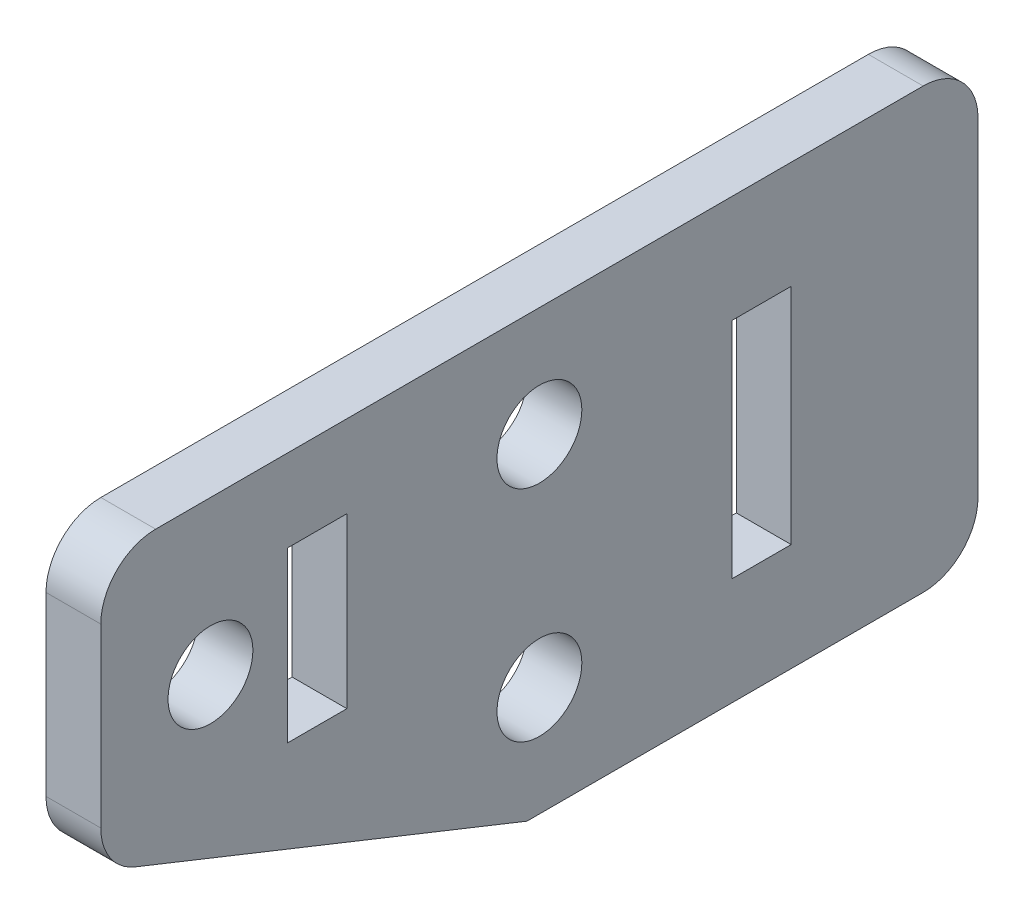
from build123d import *

# Parameters (mm, degrees)
SKETCH2_W                    = 50.8
SKETCH2_H                    = 25.4
BOSS_EXTRUDE1_DEPTH          = 3.175
CUT_EXTRUDE2_DEPTH           = 4.175
FILLET2_R                    = 3.175
SKETCH5_W                    = 3.429
SKETCH5_H                    = 9.779
SKETCH5_H_2                  = 12.954
CUT_EXTRUDE3_DEPTH           = 4.175
F_10_0_1935_DIAMETER_HOLE1_D = 4.9149


with BuildPart() as part:
    # Sketch2 → Boss-Extrude1 (new body)
    with BuildSketch(Plane(origin=(0, 0, 0), x_dir=(0, 0, -1), z_dir=(1, 0, 0))):
        Rectangle(SKETCH2_W, SKETCH2_H)
    extrude(amount=BOSS_EXTRUDE1_DEPTH)

    # Sketch4 → Cut-Extrude2 (cut, through all)
    with BuildSketch(Plane(origin=(3.175, 0, 0), x_dir=(0, 0, -1), z_dir=(1, 0, 0))):
        Polygon((0, -12.98702), (-25.4, -12.7), (-46.852380557, -12.7), (-46.852380557, 5.701326041), (-22.403810306, -4.050651033), align=None)
    extrude(amount=-CUT_EXTRUDE2_DEPTH, mode=Mode.SUBTRACT)

    # Fillet2
    fillet2_edges = [part.edges().sort_by_distance(p)[0] for p in [
        (1.5875, -2.855539298, 25.4),
        (1.5875, 12.7, 25.4),
        (1.5875, 12.7, -25.4),
        (1.5875, -12.7, -25.4),
    ]]
    fillet(fillet2_edges, radius=FILLET2_R)

    # Sketch5 → Cut-Extrude3 (cut, through all)
    with BuildSketch(Plane(origin=(3.175, 0, 0), x_dir=(0, 0, -1), z_dir=(1, 0, 0))):
        with Locations((-12.8651, 3.048)):
            Rectangle(SKETCH5_W, SKETCH5_H)
        with Locations((12.8651, 0)):
            Rectangle(SKETCH5_W, SKETCH5_H_2)
    extrude(amount=-CUT_EXTRUDE3_DEPTH, mode=Mode.SUBTRACT)

    # #10 (0.1935) Diameter Hole1 (through all)
    with Locations(Plane(origin=(3.175, 0, 0), x_dir=(0, 0, -1), z_dir=(1, 0, 0))):
        with Locations((-19.05, 3.81), (0, -6.35), (0, 6.35)):
            Hole(F_10_0_1935_DIAMETER_HOLE1_D / 2)


solid = part.part
